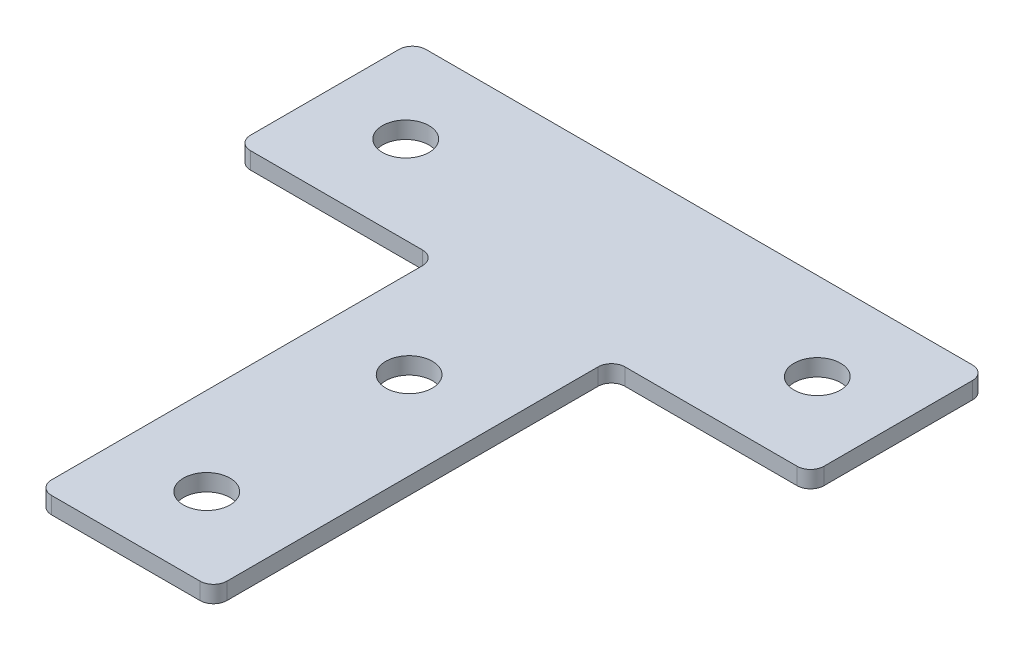
from build123d import *

# Parameters (mm, degrees)
SKETCH_1_R      = 3.45
EXTRUDE_1_DEPTH = 2.5
FILLET_1_R      = 2


with BuildPart() as part:
    # 草图1 → 凸台-拉伸1 (new body)
    with BuildSketch(Plane(origin=(0, 0, 0), x_dir=(1, 0, 0), z_dir=(0, 1, 0))):
        Polygon((13, -13), (42.5, -13), (42.5, 13), (-42.5, 13), (-42.5, -13), (-13, -13), (-13, -72), (13, -72), align=None)
        with Locations((0, -60)):
            Circle(SKETCH_1_R, mode=Mode.SUBTRACT)
        with Locations((0, -30)):
            Circle(SKETCH_1_R, mode=Mode.SUBTRACT)
        with Locations((-30.5, 0)):
            Circle(SKETCH_1_R, mode=Mode.SUBTRACT)
        with Locations((30.5, 0)):
            Circle(SKETCH_1_R, mode=Mode.SUBTRACT)
    extrude(amount=EXTRUDE_1_DEPTH)

    # 圆角1
    fillet_1_edges = [part.edges().sort_by_distance(p)[0] for p in [
        (42.5, 1.25, 13),
        (13, 1.25, 13),
        (13, 1.25, 72),
        (-13, 1.25, 72),
        (-13, 1.25, 13),
        (-42.5, 1.25, 13),
        (-42.5, 1.25, -13),
        (42.5, 1.25, -13),
    ]]
    fillet(fillet_1_edges, radius=FILLET_1_R)


solid = part.part
